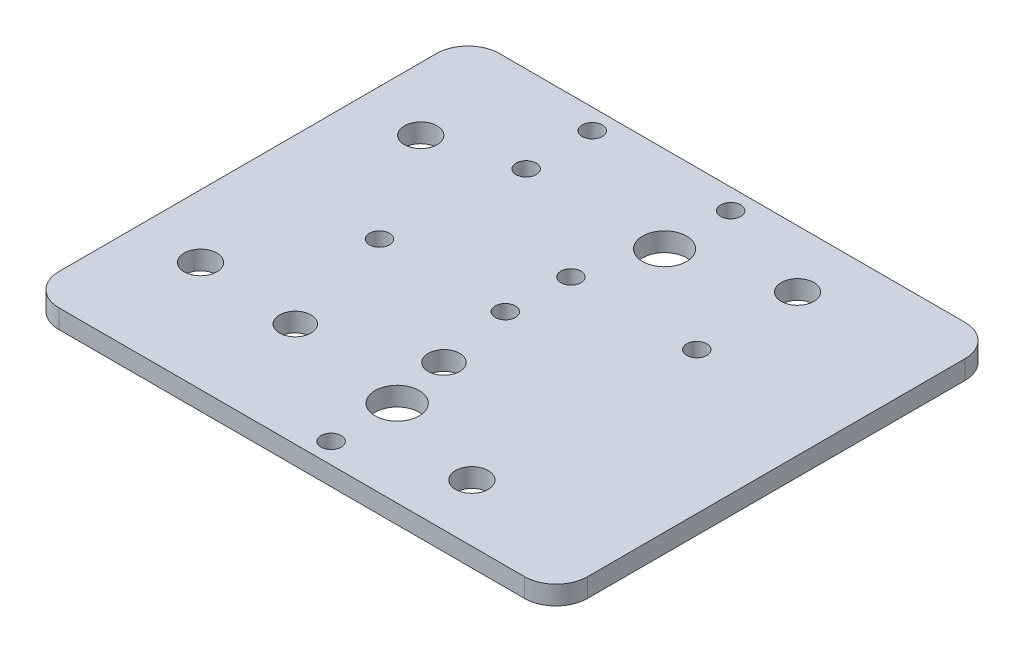
from build123d import *

# Parameters (mm, degrees)
SKETCH_1_W             = 35
SKETCH_1_H             = 70
SKETCH_1_R             = 2.6
EXTRUDE_528_DEPTH      = 3
SKETCH_2_R             = 2.1
CUT_EXTRUDE_M4_DEPTH   = 3
SKETCH_3_R             = 2.6
EXTRUDE_990_DEPTH      = 3
SKETCH_4_R             = 2.1
CUT_EXTRUDE_1335_DEPTH = 4
SKETCH_5_W             = 49
SKETCH_5_H             = 70
EXTRA_DEPTH            = 3
SKETCH_6_R             = 2.1
CUT_EXTRUDE_2079_DEPTH = 10
SKETCH_7_R             = 2.1
ETRA_DEPTH             = 10
SKETCH_10_R            = 1.6
SKETCH_10_R_2          = 3.5
CUT_EXTRUDE_3705_DEPTH = 4
FILLET_5_0_R           = 5
SKETCH_12_R            = 2.1
EXTRUDE_1_DEPTH        = 3
SKETCH_13_R            = 1.5
CUT_EXTRUDE_1_DEPTH    = 4
SKETCH_14_R            = 1.5
EXTRUDE_2_DEPTH        = 3
SKETCH_15_R            = 2.5
CUT_EXTRUDE_2_DEPTH    = 4
SKETCH_16_R            = 2.6
EXTRUDE_3_DEPTH        = 3
SKETCH_18_R            = 2.5
CUT_EXTRUDE_3_DEPTH    = 3
SKETCH_19_R            = 2.180798689
SKETCH_19_R_2          = 1.661770768
EXTRUDE_4_DEPTH        = 3
SKETCH_20_R            = 2.5
CUT_EXTRUDE_4_DEPTH    = 4
SKETCH_21_R            = 1.5
SKETCH_21_R_2          = 2.5
SKETCH_21_R_3          = 2.1
EXTRUDE_5_DEPTH        = 3
SKETCH_22_R            = 1.5
CUT_EXTRUDE_5_DEPTH    = 4
SKETCH_23_R            = 1.5
EXTRUDE_6_DEPTH        = 3
SKETCH_24_R            = 1.2
CUT_EXTRUDE_8_DEPTH    = 4
SKETCH_26_R            = 1.5
CUT_EXTRUDE_10_DEPTH   = 4
SKETCH_27_R            = 1.2
SKETCH_27_R_2          = 1.228912634
EXTRUDE_7_DEPTH        = 3
SKETCH_28_R            = 2.5
EXTRUDE_8_DEPTH        = 3
SKETCH_29_R            = 1.2
CUT_EXTRUDE_11_DEPTH   = 4
SKETCH_30_R            = 1.5
EXTRUDE_9_DEPTH        = 3
SKETCH_31_R            = 2.5
CUT_EXTRUDE_12_DEPTH   = 4
SKETCH_32_R            = 2.622023652
SKETCH_32_R_2          = 2.1
EXTRUDE_10_DEPTH       = 3
SKETCH_34_R            = 2.5
EXTRUDE_11_DEPTH       = 3
SKETCH_35_R            = 1.2
CUT_EXTRUDE_13_DEPTH   = 4
SKETCH_37_R            = 1.6
SKETCH_37_R_2          = 2.6
CUT_EXTRUDE_14_DEPTH   = 4


with BuildPart() as part:
    # 草图1 → Extrude 528 (new body)
    with BuildSketch(Plane(origin=(0, 0, 0), x_dir=(1, 0, 0), z_dir=(0, 1, 0))):
        Rectangle(SKETCH_1_W, SKETCH_1_H)
        with Locations((-7.5, 22.5)):
            Circle(SKETCH_1_R, mode=Mode.SUBTRACT)
        with Locations((-7.5, 0)):
            Circle(SKETCH_1_R, mode=Mode.SUBTRACT)
        with Locations((-7.5, -22.5)):
            Circle(SKETCH_1_R, mode=Mode.SUBTRACT)
        with Locations((-7.5, 10)):
            Circle(SKETCH_1_R, mode=Mode.SUBTRACT)
        with Locations((-7.5, -10)):
            Circle(SKETCH_1_R, mode=Mode.SUBTRACT)
    extrude(amount=EXTRUDE_528_DEPTH)

    # 草图2 → M4铝柱 (cut)
    with BuildSketch(Plane(origin=(0, 3, 0), x_dir=(1, 0, 0), z_dir=(0, 1, 0))):
        with Locations((10, 0)):
            Circle(SKETCH_2_R)
    extrude(amount=-CUT_EXTRUDE_M4_DEPTH, mode=Mode.SUBTRACT)

    # 草图3 → Extrude 990 (add, through all)
    with BuildSketch(Plane(origin=(0, 3, 0), x_dir=(1, 0, 0), z_dir=(0, 1, 0))):
        with Locations((-7.5, -10)):
            Circle(SKETCH_3_R)
        with Locations((-7.5, 10)):
            Circle(SKETCH_3_R)
    extrude(amount=-EXTRUDE_990_DEPTH)

    # 草图4 → Cut-Extrude 1335 (cut, through all)
    with BuildSketch(Plane(origin=(0, 3, 0), x_dir=(1, 0, 0), z_dir=(0, 1, 0))):
        with Locations((10, 22.5)):
            Circle(SKETCH_4_R)
        with Locations((10, -22.5)):
            Circle(SKETCH_4_R)
    extrude(amount=-CUT_EXTRUDE_1335_DEPTH, mode=Mode.SUBTRACT)

    # 草图5 → EXTRA (add, through all)
    with BuildSketch(Plane(origin=(0, 3, 0), x_dir=(1, 0, 0), z_dir=(0, 1, 0))):
        with Locations((-42, 0)):
            Rectangle(SKETCH_5_W, SKETCH_5_H)
    extrude(amount=-EXTRA_DEPTH)

    # 草图6 → Cut-Extrude 2079 (cut)
    with BuildSketch(Plane(origin=(0, 3, 0), x_dir=(1, 0, 0), z_dir=(0, 1, 0))):
        with Locations((-44.5, 0)):
            Circle(SKETCH_6_R)
        with Locations((-36.5, 0)):
            Circle(SKETCH_6_R)
    extrude(amount=-CUT_EXTRUDE_2079_DEPTH, mode=Mode.SUBTRACT)

    # 草图7 → ETRA铝柱 (cut)
    with BuildSketch(Plane(origin=(0, 3, 0), x_dir=(1, 0, 0), z_dir=(0, 1, 0))):
        with Locations((-56.5, 17.5)):
            Circle(SKETCH_7_R)
        with Locations((-56.5, -17.5)):
            Circle(SKETCH_7_R)
    extrude(amount=-ETRA_DEPTH, mode=Mode.SUBTRACT)

    # 草图10 → Cut-Extrude 3705 (cut, through all)
    with BuildSketch(Plane.XZ):
        with Locations((-43.5, -21.25)):
            Circle(SKETCH_10_R)
        with Locations((-21.5, -31.75)):
            Circle(SKETCH_10_R)
        with Locations((-43.5, -31.75)):
            Circle(SKETCH_10_R)
        with Locations((-43.5, 21.25)):
            Circle(SKETCH_10_R)
        with Locations((-21.5, 31.75)):
            Circle(SKETCH_10_R)
        with Locations((-43.5, 31.75)):
            Circle(SKETCH_10_R)
        with Locations((-21.5, 21.25)):
            Circle(SKETCH_10_R_2)
        with Locations((-21.5, -21.25)):
            Circle(SKETCH_10_R_2)
    extrude(amount=-CUT_EXTRUDE_3705_DEPTH, mode=Mode.SUBTRACT)

    # 圆角5.0
    fillet_5_0_edges = [part.edges().sort_by_distance(p)[0] for p in [
        (-66.5, 1.5, 35),
        (-66.5, 1.5, -35),
        (17.5, 1.5, 35),
        (17.5, 1.5, -35),
    ]]
    fillet(fillet_5_0_edges, radius=FILLET_5_0_R)

    # 草图12 → 凸台-拉伸1 (add)
    with BuildSketch(Plane(origin=(0, 3, 0), x_dir=(1, 0, 0), z_dir=(0, 1, 0))):
        with Locations((-36.5, 0)):
            Circle(SKETCH_12_R)
        with Locations((-44.5, 0)):
            Circle(SKETCH_12_R)
    extrude(amount=-EXTRUDE_1_DEPTH)

    # 草图13 → 切除-拉伸1 (cut, through all)
    with BuildSketch(Plane(origin=(0, 3, 0), x_dir=(1, 0, 0), z_dir=(0, 1, 0))):
        with Locations((-52.499999555, 1.426e-06)):
            Circle(SKETCH_13_R)
        with Locations((-28.499999555, 1.44e-06)):
            Circle(SKETCH_13_R)
    extrude(amount=-CUT_EXTRUDE_1_DEPTH, mode=Mode.SUBTRACT)

    # 草图14 → 凸台-拉伸2 (add)
    with BuildSketch(Plane(origin=(0, 3, 0), x_dir=(1, 0, 0), z_dir=(0, 1, 0))):
        with Locations((-28.499999555, 1.44e-06)):
            Circle(SKETCH_14_R)
    extrude(amount=-EXTRUDE_2_DEPTH)

    # 草图15 → 切除-拉伸2 (cut, through all)
    with BuildSketch(Plane(origin=(0, 3, 0), x_dir=(1, 0, 0), z_dir=(0, 1, 0))):
        with Locations((-23.393651392, 12.166497951)):
            Circle(SKETCH_15_R)
        with Locations((-23.393651594, -11.919830539)):
            Circle(SKETCH_15_R)
    extrude(amount=-CUT_EXTRUDE_2_DEPTH, mode=Mode.SUBTRACT)

    # 草图16 → 凸台-拉伸3 (add)
    with BuildSketch(Plane(origin=(0, 3, 0), x_dir=(1, 0, 0), z_dir=(0, 1, 0))):
        with Locations((-7.5, 22.5)):
            Circle(SKETCH_16_R)
        with Locations((-7.5, 0)):
            Circle(SKETCH_16_R)
        with Locations((-7.5, -22.5)):
            Circle(SKETCH_16_R)
    extrude(amount=-EXTRUDE_3_DEPTH)

    # 草图18 → 切除-拉伸3 (cut)
    with BuildSketch(Plane.XZ):
        with Locations((-3.558761246, 0)):
            Circle(SKETCH_18_R)
        with Locations((-3.558761246, 22.202338419)):
            Circle(SKETCH_18_R)
        with Locations((-3.558761246, -23.518793957)):
            Circle(SKETCH_18_R)
    extrude(amount=-CUT_EXTRUDE_3_DEPTH, mode=Mode.SUBTRACT)

    # 草图19 → 凸台-拉伸4 (add)
    with BuildSketch(Plane.XZ):
        with Locations((-43.5, 21.25)):
            Circle(SKETCH_19_R)
        with Locations((-43.5, 31.75)):
            Circle(SKETCH_19_R_2)
    extrude(amount=-EXTRUDE_4_DEPTH)

    # 草图20 → 切除-拉伸4 (cut, through all)
    with BuildSketch(Plane(origin=(0, 3, 0), x_dir=(1, 0, 0), z_dir=(0, 1, 0))):
        with Locations((-40.5, 1.551947464)):
            Circle(SKETCH_20_R)
        with Locations((-40.5, -18.448052536)):
            Circle(SKETCH_20_R)
    extrude(amount=-CUT_EXTRUDE_4_DEPTH, mode=Mode.SUBTRACT)

    # 草图21 → 凸台-拉伸5 (add)
    with BuildSketch(Plane(origin=(0, 3, 0), x_dir=(1, 0, 0), z_dir=(0, 1, 0))):
        with Locations((-52.499999555, 1.426e-06)):
            Circle(SKETCH_21_R)
        with Locations((-40.5, 1.551947464)):
            Circle(SKETCH_21_R_2)
        with Locations((-3.558761246, 0)):
            Circle(SKETCH_21_R_2)
        with Locations((10, 0)):
            Circle(SKETCH_21_R_3)
    extrude(amount=-EXTRUDE_5_DEPTH)

    # 草图22 → 切除-拉伸5 (cut, through all)
    with BuildSketch(Plane(origin=(0, 3, 0), x_dir=(1, 0, 0), z_dir=(0, 1, 0))):
        with Locations((-52.5, 0)):
            Circle(SKETCH_22_R)
        with Locations((-28.5, 0)):
            Circle(SKETCH_22_R)
    extrude(amount=-CUT_EXTRUDE_5_DEPTH, mode=Mode.SUBTRACT)

    # 草图23 → 凸台-拉伸6 (add)
    with BuildSketch(Plane(origin=(0, 3, 0), x_dir=(1, 0, 0), z_dir=(0, 1, 0))):
        with Locations((-52.5, 0)):
            Circle(SKETCH_23_R)
        with Locations((-28.5, 0)):
            Circle(SKETCH_23_R)
    extrude(amount=-EXTRUDE_6_DEPTH)

    # 草图24 → 切除-拉伸8 (cut, through all)
    with BuildSketch(Plane(origin=(0, 3, 0), x_dir=(1, 0, 0), z_dir=(0, 1, 0))):
        with Locations((-45.5, -0.064794531)):
            Circle(SKETCH_24_R)
        with Locations((-25.5, -0.064794531)):
            Circle(SKETCH_24_R)
    extrude(amount=-CUT_EXTRUDE_8_DEPTH, mode=Mode.SUBTRACT)

    # 草图26 → 切除-拉伸10 (cut, through all)
    with BuildSketch(Plane.XZ):
        with Locations((-52.5, 0)):
            Circle(SKETCH_26_R)
        with Locations((-28.5, 0)):
            Circle(SKETCH_26_R)
    extrude(amount=-CUT_EXTRUDE_10_DEPTH, mode=Mode.SUBTRACT)

    # 草图27 → 凸台-拉伸7 (add)
    with BuildSketch(Plane(origin=(0, 0, 0), x_dir=(-1, 0, 0), z_dir=(0, -1, 0))):
        with Locations((25.5, -0.064794531)):
            Circle(SKETCH_27_R)
        with Locations((45.5, -0.064794531)):
            Circle(SKETCH_27_R_2)
    extrude(amount=-EXTRUDE_7_DEPTH)

    # 草图28 → 凸台-拉伸8 (add)
    with BuildSketch(Plane(origin=(0, 3, 0), x_dir=(1, 0, 0), z_dir=(0, 1, 0))):
        with Locations((-3.558761246, -22.202338419)):
            Circle(SKETCH_28_R)
        with Locations((-3.558761246, 23.518793957)):
            Circle(SKETCH_28_R)
    extrude(amount=-EXTRUDE_8_DEPTH)

    # 草图29 → 切除-拉伸11 (cut, through all)
    with BuildSketch(Plane(origin=(0, 3, 0), x_dir=(1, 0, 0), z_dir=(0, 1, 0))):
        with Locations((-25.5, -0.064794531)):
            Circle(SKETCH_29_R)
        with Locations((-45.5, -0.064794531)):
            Circle(SKETCH_29_R)
    extrude(amount=-CUT_EXTRUDE_11_DEPTH, mode=Mode.SUBTRACT)

    # 草图30 → 凸台-拉伸9 (add)
    with BuildSketch(Plane(origin=(0, 3, 0), x_dir=(1, 0, 0), z_dir=(0, 1, 0))):
        with Locations((-28.5, 0)):
            Circle(SKETCH_30_R)
        with Locations((-52.5, 0)):
            Circle(SKETCH_30_R)
    extrude(amount=-EXTRUDE_9_DEPTH)

    # 草图31 → 切除-拉伸12 (cut, through all)
    with BuildSketch(Plane.XZ):
        with Locations((-5, 25.879055361)):
            Circle(SKETCH_31_R)
        with Locations((-5, -25.879055361)):
            Circle(SKETCH_31_R)
    extrude(amount=-CUT_EXTRUDE_12_DEPTH, mode=Mode.SUBTRACT)

    # 草图32 → 凸台-拉伸10 (add)
    with BuildSketch(Plane(origin=(0, 3, 0), x_dir=(1, 0, 0), z_dir=(0, 1, 0))):
        with Locations((10, -22.5)):
            Circle(SKETCH_32_R)
        with Locations((10, 22.5)):
            Circle(SKETCH_32_R_2)
    extrude(amount=-EXTRUDE_10_DEPTH)

    # 草图34 → 凸台-拉伸11 (add)
    with BuildSketch(Plane(origin=(0, 3, 0), x_dir=(1, 0, 0), z_dir=(0, 1, 0))):
        with Locations((-23.393651392, 12.166497951)):
            Circle(SKETCH_34_R)
    extrude(amount=-EXTRUDE_11_DEPTH)

    # 草图35 → 切除-拉伸13 (cut, through all)
    with BuildSketch(Plane(origin=(0, 3, 0), x_dir=(1, 0, 0), z_dir=(0, 1, 0))):
        with Locations((-5.06603585, 9.935205469)):
            Circle(SKETCH_35_R)
        with Locations((-25.06603585, 9.935205469)):
            Circle(SKETCH_35_R)
    extrude(amount=-CUT_EXTRUDE_13_DEPTH, mode=Mode.SUBTRACT)

    # 草图37 → 切除-拉伸14 (cut, through all)
    with BuildSketch(Plane(origin=(0, 3, 0), x_dir=(1, 0, 0), z_dir=(0, 1, 0))):
        with Locations((-45.5, -0.064794531)):
            Circle(SKETCH_37_R)
        with Locations((-25.5, -0.064794531)):
            Circle(SKETCH_37_R)
        with Locations((-25.06603585, 9.935205469)):
            Circle(SKETCH_37_R)
        with Locations((-5.06603585, 9.935205469)):
            Circle(SKETCH_37_R)
        with Locations((-5, 25.879055361)):
            Circle(SKETCH_37_R_2)
        with Locations((-5, -25.879055361)):
            Circle(SKETCH_37_R_2)
        with Locations((-56.5, 17.5)):
            Circle(SKETCH_37_R_2)
        with Locations((-56.5, -17.5)):
            Circle(SKETCH_37_R_2)
    extrude(amount=-CUT_EXTRUDE_14_DEPTH, mode=Mode.SUBTRACT)


solid = part.part
